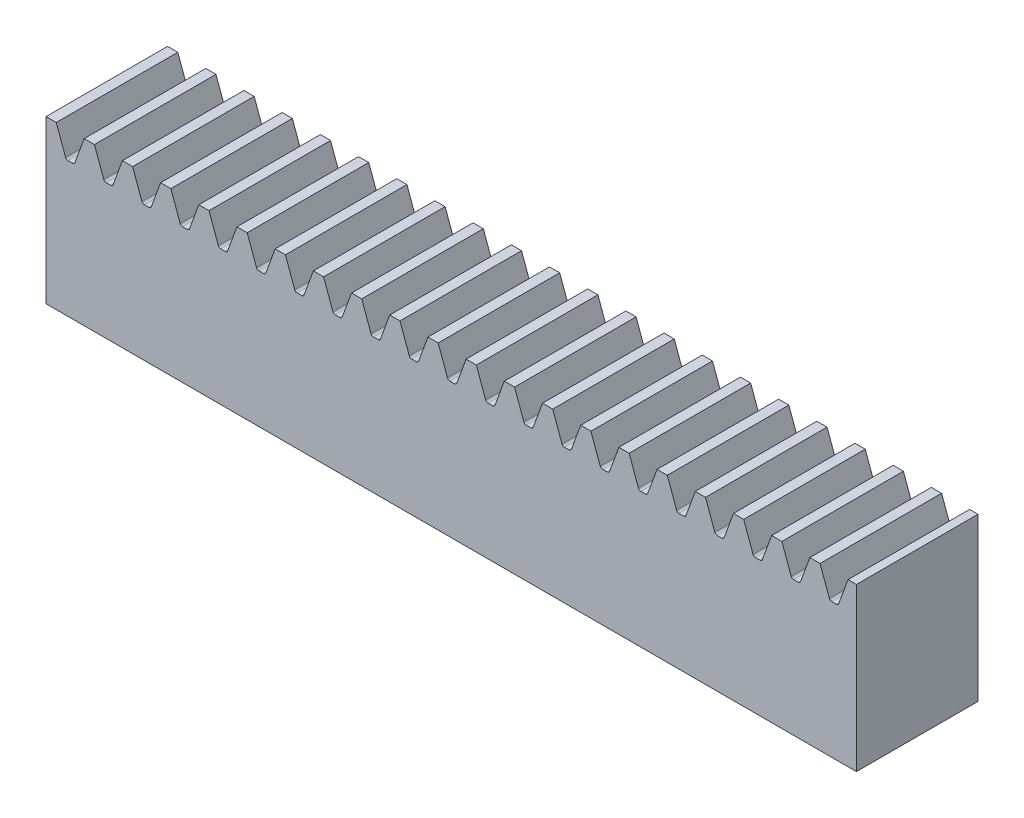
from build123d import *

# Parameters (mm, degrees)
SKETCH2_W                = 15
SKETCH2_H                = 20
BOSS_EXTRUDE1_DEPTH      = 50
BOSS_EXTRUDE1_DEPTH_BACK = 50
CUT_EXTRUDE1_DEPTH       = 8.5
FILLET1_R                = 0.302678334
LPATTERN1_COUNT          = 21
LPATTERN1_PITCH          = 4.7124
FILLET1_OF_LPATTERN1_R   = 0.302678334


with BuildPart() as part:
    # Sketch2 → Boss-Extrude1 (new body, two sides)
    with BuildSketch(Plane(origin=(0, 0, 0), x_dir=(0, 0, -1), z_dir=(1, 0, 0))) as boss_extrude1_sk:
        with Locations((0, 10)):
            Rectangle(SKETCH2_W, SKETCH2_H)
    extrude(amount=BOSS_EXTRUDE1_DEPTH)
    extrude(boss_extrude1_sk.sketch, amount=-BOSS_EXTRUDE1_DEPTH_BACK)

    # Sketch3 → Cut-Extrude1 (cut, symmetric)
    with BuildSketch(Plane.XY):
        Polygon((-48.735710703, 20), (-47.516119242, 16.6492), (-46.507191461, 16.6492), (-45.2876, 20), align=None)
    cut_extrude1 = extrude(amount=CUT_EXTRUDE1_DEPTH, both=True, mode=Mode.SUBTRACT)

    # Fillet1
    fillet1_edges = [part.edges().sort_by_distance(p)[0] for p in [
        (-46.507191461, 16.6492, 0),
        (-47.516119242, 16.6492, 0),
    ]]
    fillet(fillet1_edges, radius=FILLET1_R)

    # LPattern1: Cut-Extrude1 ×21
    with Locations(*[(i * LPATTERN1_PITCH, 0, 0) for i in range(1, LPATTERN1_COUNT)]):
        add(cut_extrude1, mode=Mode.SUBTRACT)

    # Fillet1 of LPattern1
    fillet1_of_lpattern1_edges = [part.edges().sort_by_distance(p)[0] for p in [
        (-41.794791461, 16.6492, 0),
        (-42.803719242, 16.6492, 0),
        (-37.082391461, 16.6492, 0),
        (-38.091319242, 16.6492, 0),
        (-32.369991461, 16.6492, 0),
        (-33.378919242, 16.6492, 0),
        (-27.657591461, 16.6492, 0),
        (-28.666519242, 16.6492, 0),
        (-22.945191461, 16.6492, 0),
        (-23.954119242, 16.6492, 0),
        (-18.232791461, 16.6492, 0),
        (-19.241719242, 16.6492, 0),
        (-13.520391461, 16.6492, 0),
        (-14.529319242, 16.6492, 0),
        (-8.807991461, 16.6492, 0),
        (-9.816919242, 16.6492, 0),
        (-4.095591461, 16.6492, 0),
        (-5.104519242, 16.6492, 0),
        (0.616808539, 16.6492, 0),
        (-0.392119242, 16.6492, 0),
        (5.329208539, 16.6492, 0),
        (4.320280758, 16.6492, 0),
        (10.041608539, 16.6492, 0),
        (9.032680758, 16.6492, 0),
        (14.754008539, 16.6492, 0),
        (13.745080758, 16.6492, 0),
        (19.466408539, 16.6492, 0),
        (18.457480758, 16.6492, 0),
        (24.178808539, 16.6492, 0),
        (23.169880758, 16.6492, 0),
        (28.891208539, 16.6492, 0),
        (27.882280758, 16.6492, 0),
        (33.603608539, 16.6492, 0),
        (32.594680758, 16.6492, 0),
        (38.316008539, 16.6492, 0),
        (37.307080758, 16.6492, 0),
        (43.028408539, 16.6492, 0),
        (42.019480758, 16.6492, 0),
        (47.740808539, 16.6492, 0),
        (46.731880758, 16.6492, 0),
    ]]
    fillet(fillet1_of_lpattern1_edges, radius=FILLET1_OF_LPATTERN1_R)


solid = part.part
